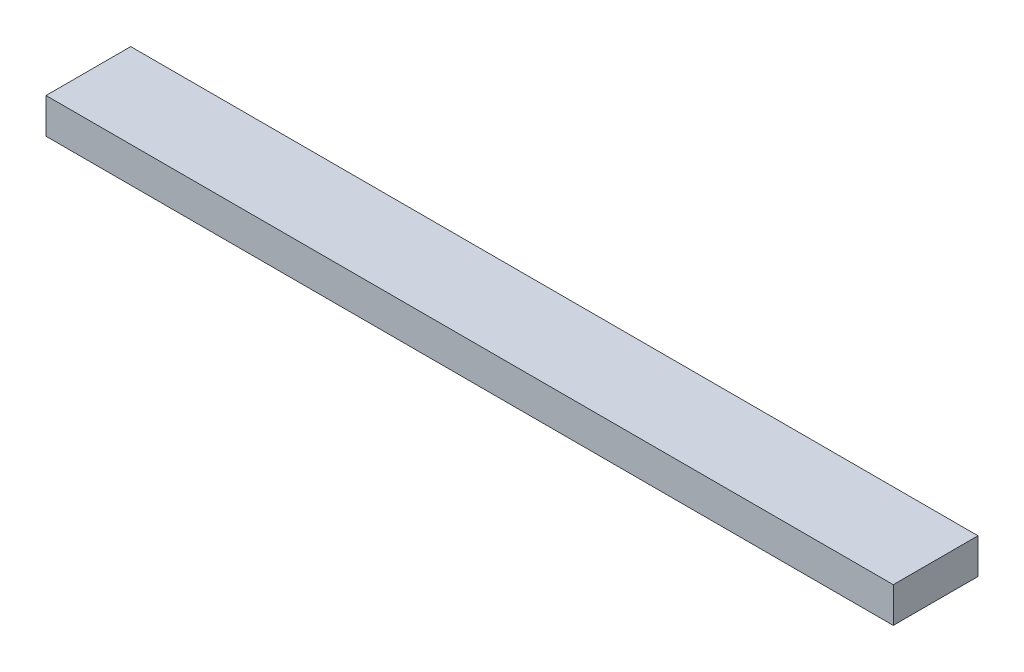
from build123d import *

# Parameters (mm, degrees)
SKETCH1_W           = 76.2
SKETCH1_H           = 7.62
BOSS_EXTRUDE1_DEPTH = 3.175


with BuildPart() as part:
    # Sketch1 → Boss-Extrude1 (new body)
    with BuildSketch(Plane(origin=(0, 0, 0), x_dir=(1, 0, 0), z_dir=(0, 1, 0))):
        Rectangle(SKETCH1_W, SKETCH1_H)
    extrude(amount=BOSS_EXTRUDE1_DEPTH)


solid = part.part
